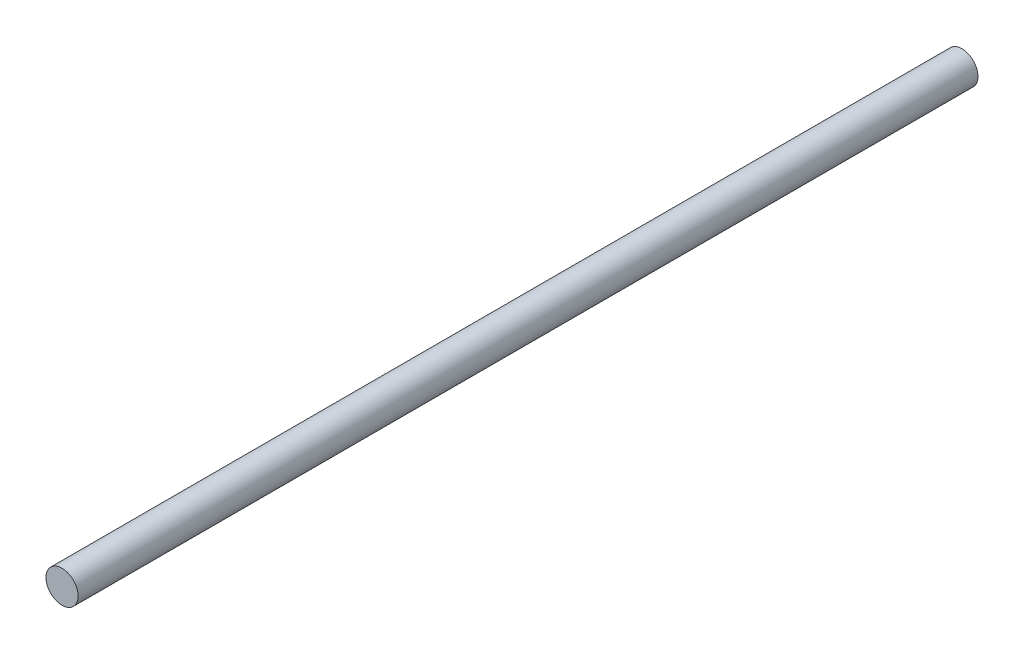
from build123d import *

# Parameters (mm, degrees)
SKETCH1_R           = 5
BOSS_EXTRUDE1_DEPTH = 280


with BuildPart() as part:
    # Sketch1 → Boss-Extrude1 (new body)
    with BuildSketch(Plane.XY):
        Circle(SKETCH1_R)
    extrude(amount=BOSS_EXTRUDE1_DEPTH)


solid = part.part
